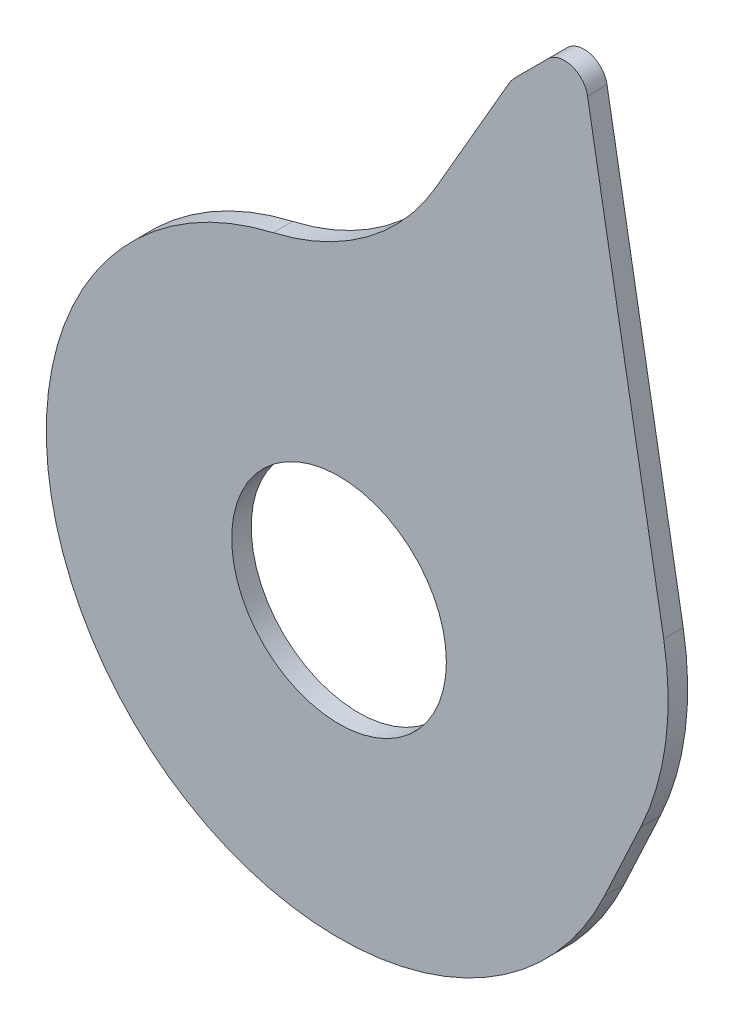
from build123d import *

# Parameters (mm, degrees)
SKETCH1_R      = 27.5
EXTRUDE1_DEPTH = 5


with BuildPart() as part:
    # Sketch1 → Extrude1 (new body)
    with BuildSketch(Plane.XY):
        with BuildLine():
            Line((24.77155023, 103.905583581), (43.516396951, 136.372610482))
            ThreePointArc((43.516396951, 136.372610482), (44.243117586, 137.460224772), (45.105583177, 138.443678294))
            Line((45.105583177, 138.443678294), (53.511867952, 146.849963069))
            ThreePointArc((53.511867952, 146.849963069), (59.558743436, 148.329624086), (63.663355157, 143.649211448))
            Line((63.663355157, 143.649211448), (83.174325272, 32.997001352))
            ThreePointArc((83.174325272, 32.997001352), (83.672108399, 10.183923611), (77.286827824, -11.722981603))
            Line((77.286827824, -11.722981603), (67.973084028, -31.696369631))
            ThreePointArc((67.973084028, -31.696369631), (-58.281283725, -47.204787547), (-16.885768401, 73.074419775))
            ThreePointArc((-16.885768401, 73.074419775), (7.148542121, 84.158707713), (24.77155023, 103.905583581))
        make_face()
        Circle(SKETCH1_R, mode=Mode.SUBTRACT)
    extrude(amount=EXTRUDE1_DEPTH)


solid = part.part
